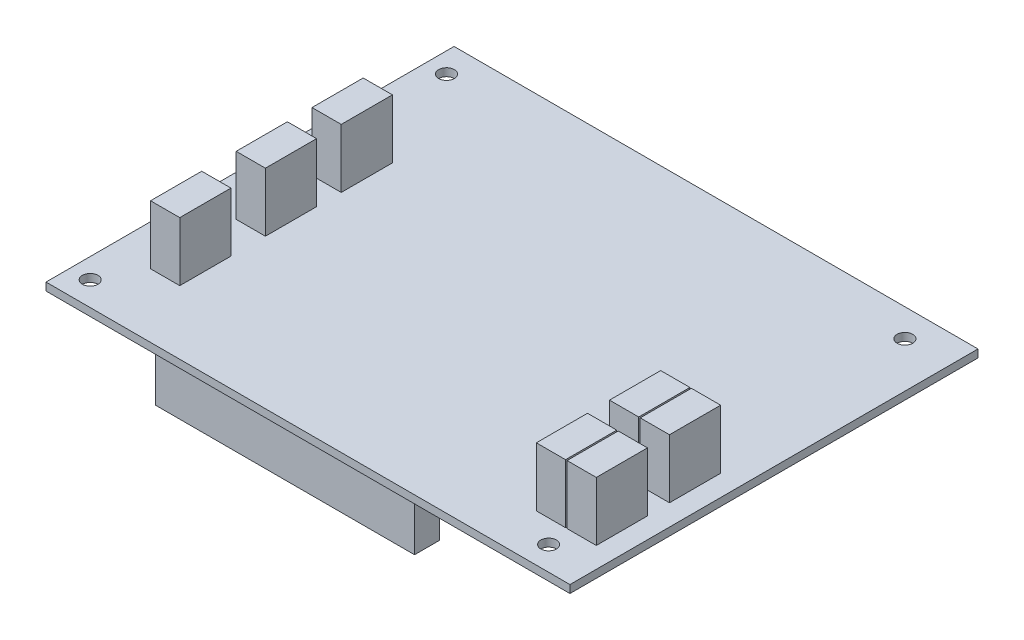
from build123d import *

# Parameters (mm, degrees)
ESQUISSE1_W      = 104
ESQUISSE1_H      = 81
ESQUISSE1_R      = 1.55
EXTRUSION2_DEPTH = 1.55
ESQUISSE2_W      = 51.46
ESQUISSE2_H      = 4.95
EXTRUSION3_DEPTH = 12.6
ESQUISSE3_W      = 5.8
ESQUISSE3_H      = 10.16
EXTRUSION4_DEPTH = 11.7
ESQUISSE4_W      = 5.8
ESQUISSE4_H      = 10.16
EXTRUSION5_DEPTH = 11.7


with BuildPart() as part:
    # Esquisse1 → Extrusion2 (new body)
    with BuildSketch(Plane(origin=(0, 0, 0), x_dir=(1, 0, 0), z_dir=(0, 1, 0))):
        with Locations((31, 37)):
            Rectangle(ESQUISSE1_W, ESQUISSE1_H)
        with Locations((-17, 1.27)):
            Circle(ESQUISSE1_R, mode=Mode.SUBTRACT)
        with Locations((-17, 72)):
            Circle(ESQUISSE1_R, mode=Mode.SUBTRACT)
        with Locations((74, 72)):
            Circle(ESQUISSE1_R, mode=Mode.SUBTRACT)
        with Locations((74, 1.27)):
            Circle(ESQUISSE1_R, mode=Mode.SUBTRACT)
    extrude(amount=EXTRUSION2_DEPTH)

    # Esquisse2 → Extrusion3 (add)
    with BuildSketch(Plane(origin=(0, 1.55, 0), x_dir=(-1, 0, 0), z_dir=(0, 1, 0))):
        with Locations((-24.13, -72)):
            Rectangle(ESQUISSE2_W, ESQUISSE2_H)
        with Locations((-24.13, -1.27)):
            Rectangle(ESQUISSE2_W, ESQUISSE2_H)
    extrude(amount=-EXTRUSION3_DEPTH)

    # Esquisse3 → Extrusion4 (add)
    with BuildSketch(Plane(origin=(0, 1.55, 0), x_dir=(-1, 0, 0), z_dir=(0, 1, 0))):
        with Locations((10, -31.23)):
            Rectangle(ESQUISSE3_W, ESQUISSE3_H)
        with Locations((10, -14.23)):
            Rectangle(ESQUISSE3_W, ESQUISSE3_H)
        with Locations((10, -46.282)):
            Rectangle(ESQUISSE3_W, ESQUISSE3_H)
    extrude(amount=EXTRUSION4_DEPTH)

    # Esquisse4 → Extrusion5 (add)
    with BuildSketch(Plane(origin=(0, 1.55, 0), x_dir=(-1, 0, 0), z_dir=(0, 1, 0))):
        with Locations((-69.9, -10.91)):
            Rectangle(ESQUISSE4_W, ESQUISSE4_H)
        with Locations((-76, -10.91)):
            Rectangle(ESQUISSE4_W, ESQUISSE4_H)
        with Locations((-69.825093766, -25.51)):
            Rectangle(ESQUISSE4_W, ESQUISSE4_H)
        with Locations((-75.925093766, -25.51)):
            Rectangle(ESQUISSE4_W, ESQUISSE4_H)
    extrude(amount=EXTRUSION5_DEPTH)


solid = part.part
